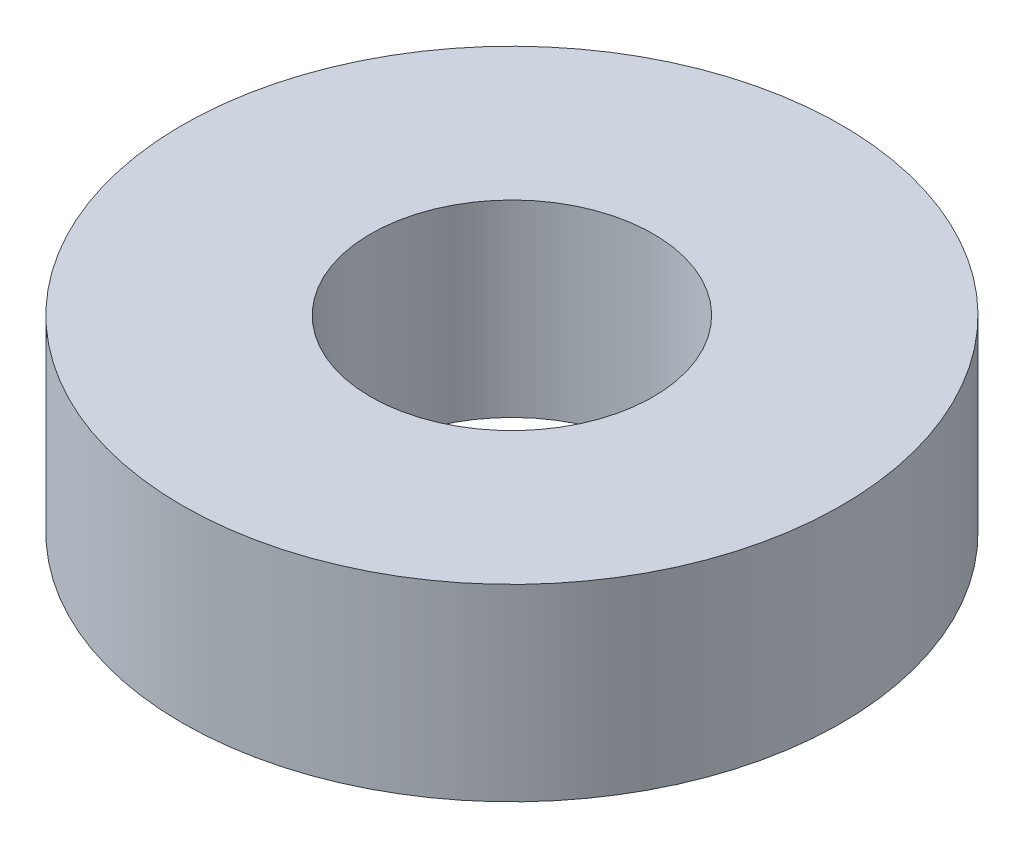
from build123d import *

# Parameters (mm, degrees)
ESQUISSE1_R        = 14
ESQUISSE1_R_2      = 6
BOSS_EXTRU_1_DEPTH = 8


with BuildPart() as part:
    # Esquisse1 → Boss.-Extru.1 (new body)
    with BuildSketch(Plane(origin=(0, 0, 0), x_dir=(1, 0, 0), z_dir=(0, 1, 0))):
        Circle(ESQUISSE1_R)
        Circle(ESQUISSE1_R_2, mode=Mode.SUBTRACT)
    extrude(amount=BOSS_EXTRU_1_DEPTH)


solid = part.part
